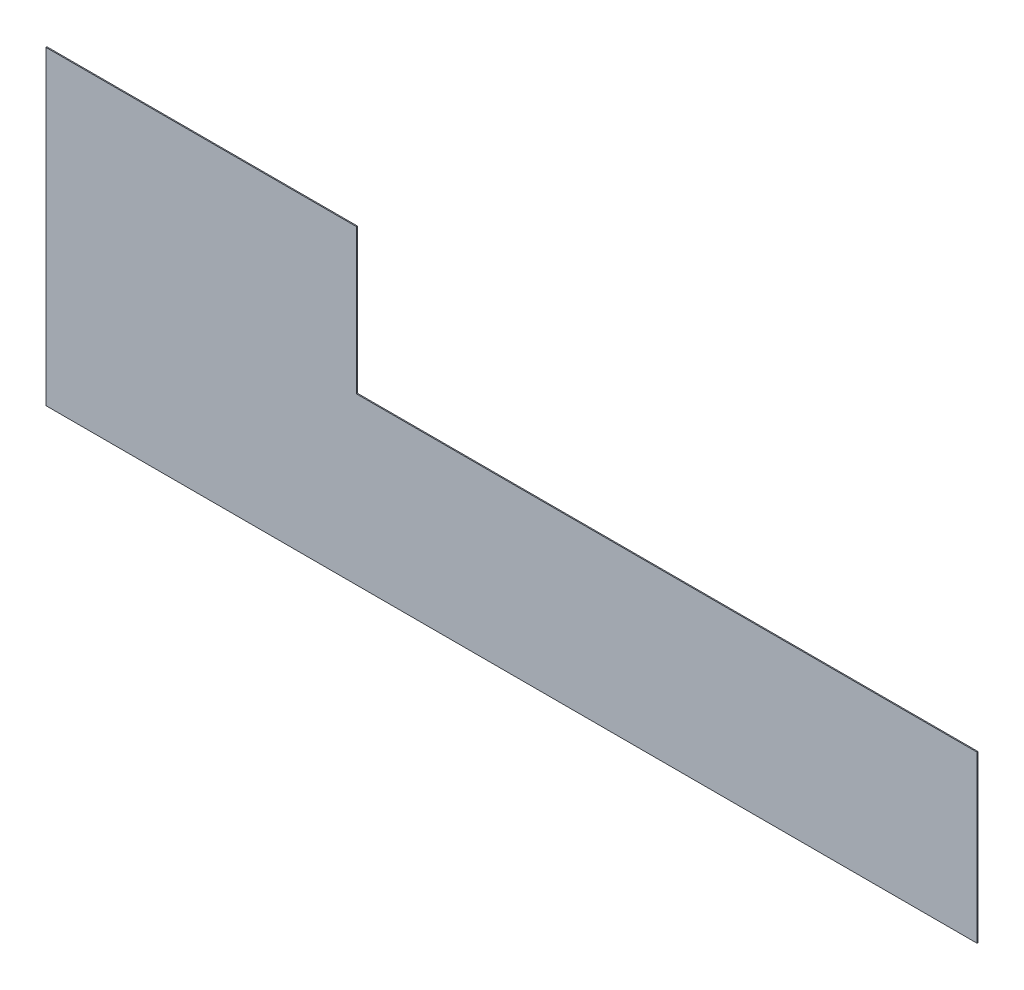
from build123d import *

# Parameters (mm, degrees)
BOSS_EXTRUDE1_DEPTH = 1


with BuildPart() as part:
    # Sketch1 → Boss-Extrude1 (new body)
    with BuildSketch(Plane.XY):
        Polygon((-444.551889529, 140), (-444.551889529, -160), (455.448110471, -160), (455.448110471, 0), (-144.551889529, 0), (-144.551889529, 140), align=None)
    extrude(amount=BOSS_EXTRUDE1_DEPTH)


solid = part.part
